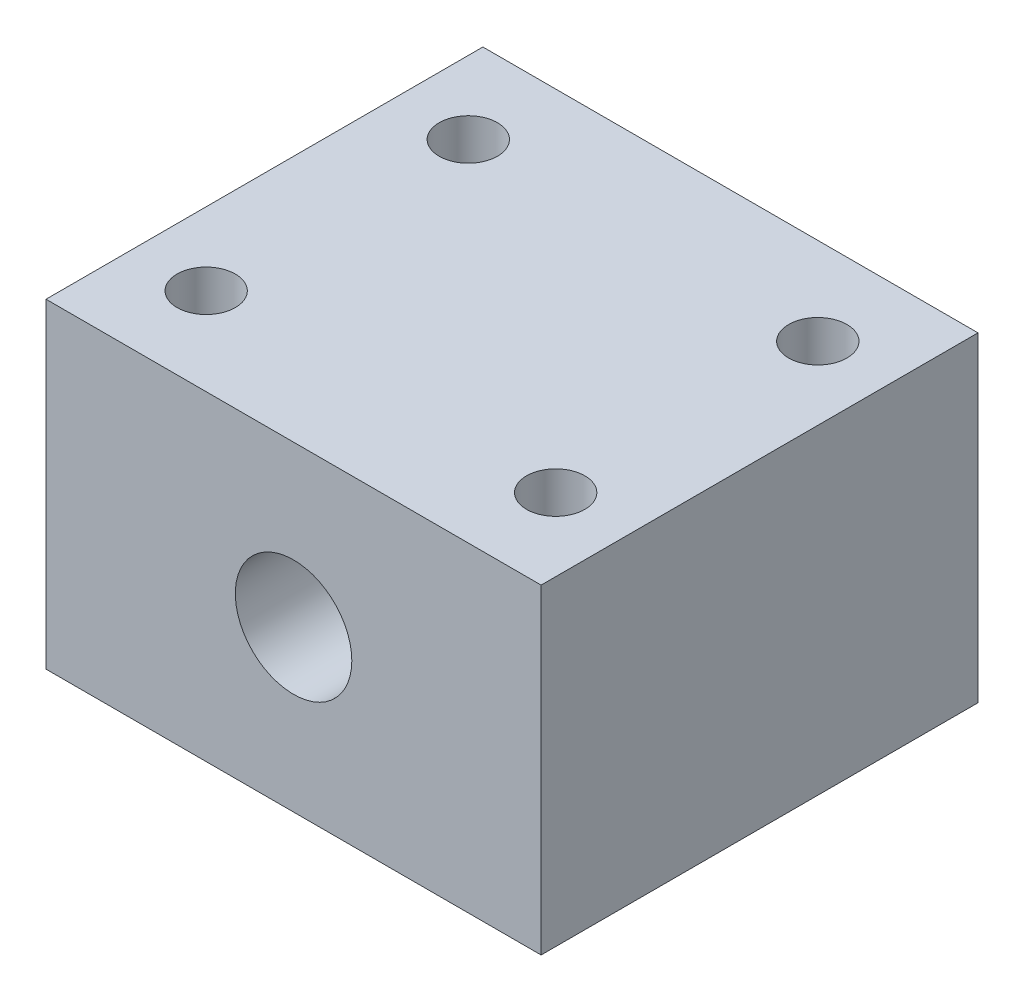
from build123d import *

# Parameters (mm, degrees)
SKETCH1_W           = 34
SKETCH1_H           = 22
SKETCH1_R           = 4
BOSS_EXTRUDE1_DEPTH = 30
SKETCH2_R           = 2
CUT_EXTRUDE1_DEPTH  = 23


with BuildPart() as part:
    # Sketch1 → Boss-Extrude1 (new body)
    with BuildSketch(Plane.XY):
        with Locations((17, 11)):
            Rectangle(SKETCH1_W, SKETCH1_H)
        with Locations((17, 11)):
            Circle(SKETCH1_R, mode=Mode.SUBTRACT)
    extrude(amount=BOSS_EXTRUDE1_DEPTH)

    # Sketch2 → Cut-Extrude1 (cut, through all)
    with BuildSketch(Plane(origin=(0, 22, 0), x_dir=(1, 0, 0), z_dir=(0, 1, 0))):
        with Locations((5, -24)):
            Circle(SKETCH2_R)
        with Locations((5, -6)):
            Circle(SKETCH2_R)
        with Locations((29, -6)):
            Circle(SKETCH2_R)
        with Locations((29, -24)):
            Circle(SKETCH2_R)
    extrude(amount=-CUT_EXTRUDE1_DEPTH, mode=Mode.SUBTRACT)


solid = part.part
